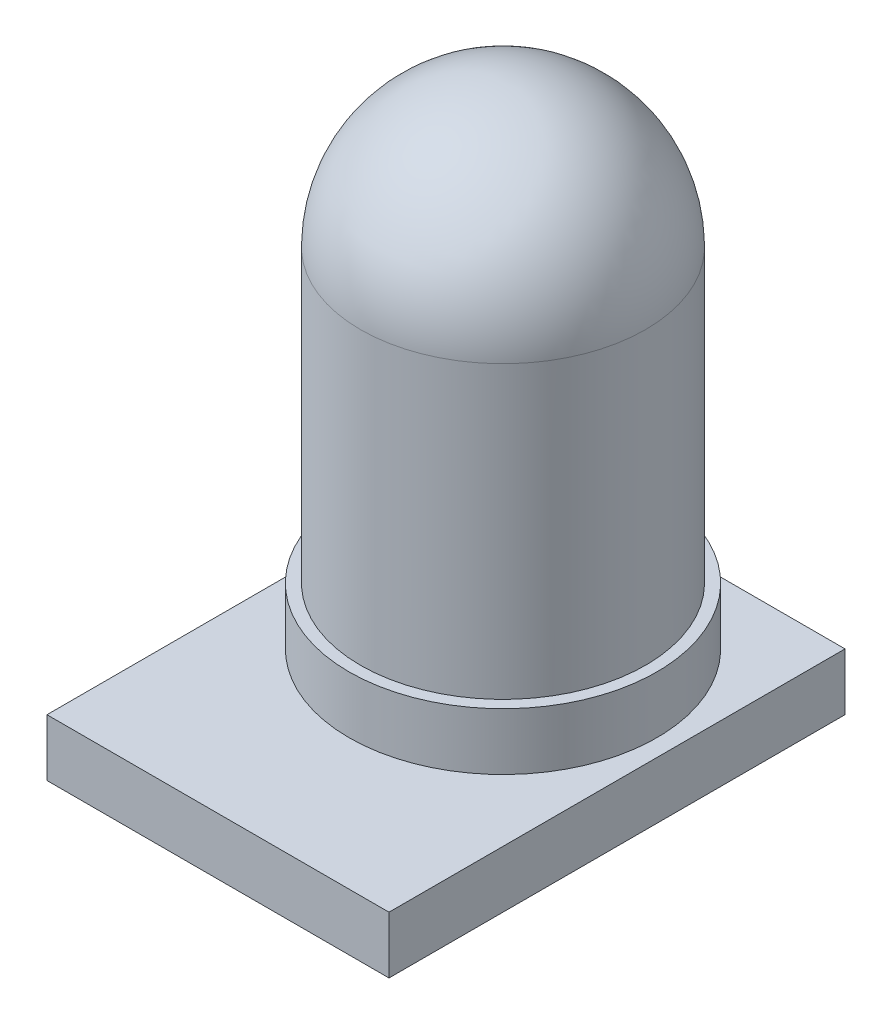
from build123d import *

# Parameters (mm, degrees)
SKETCH1_R           = 2.5
BOSS_EXTRUDE1_DEPTH = 8.6
FILLET1_R           = 2.5
BOSS_EXTRUDE2_DEPTH = 1
SKETCH3_R           = 2.7
BOSS_EXTRUDE3_DEPTH = 1


with BuildPart() as part:
    # Sketch1 → Boss-Extrude1 (new body)
    with BuildSketch(Plane(origin=(0, 0, 0), x_dir=(1, 0, 0), z_dir=(0, 1, 0))):
        Circle(SKETCH1_R)
    extrude(amount=BOSS_EXTRUDE1_DEPTH)

    # Fillet1
    fillet1_edges = [part.edges().sort_by_distance(p)[0] for p in [
        (-2.5, 8.6, 0),
    ]]
    fillet(fillet1_edges, radius=FILLET1_R)

    # Sketch2 → Boss-Extrude2 (add)
    with BuildSketch(Plane(origin=(0, 0, 0), x_dir=(-1, 0, 0), z_dir=(0, -1, 0))):
        Polygon((0, 3), (-3, 3), (-3, -5), (0, -5), (3, -5), (3, 3), align=None)
    extrude(amount=BOSS_EXTRUDE2_DEPTH)

    # Sketch3 → Boss-Extrude3 (add)
    with BuildSketch(Plane(origin=(0, 0, 0), x_dir=(1, 0, 0), z_dir=(0, 1, 0))):
        Circle(SKETCH3_R)
    extrude(amount=BOSS_EXTRUDE3_DEPTH)


solid = part.part
